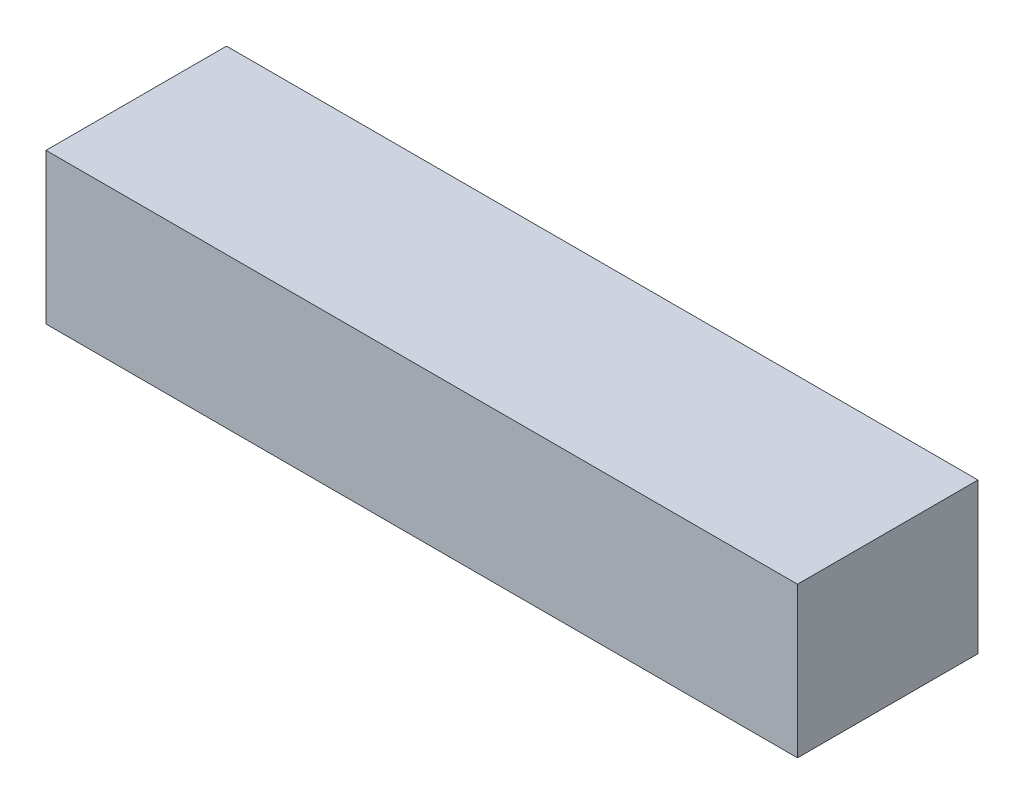
from build123d import *

# Parameters (mm, degrees)
ESQUISSE1_W        = 24.98
ESQUISSE1_H        = 5
BOSS_EXTRU_1_DEPTH = 6


with BuildPart() as part:
    # Esquisse1 → Boss.-Extru.1 (new body)
    with BuildSketch(Plane.XY):
        with Locations((1.314301239, -1.09503876)):
            Rectangle(ESQUISSE1_W, ESQUISSE1_H)
    extrude(amount=BOSS_EXTRU_1_DEPTH)


solid = part.part
